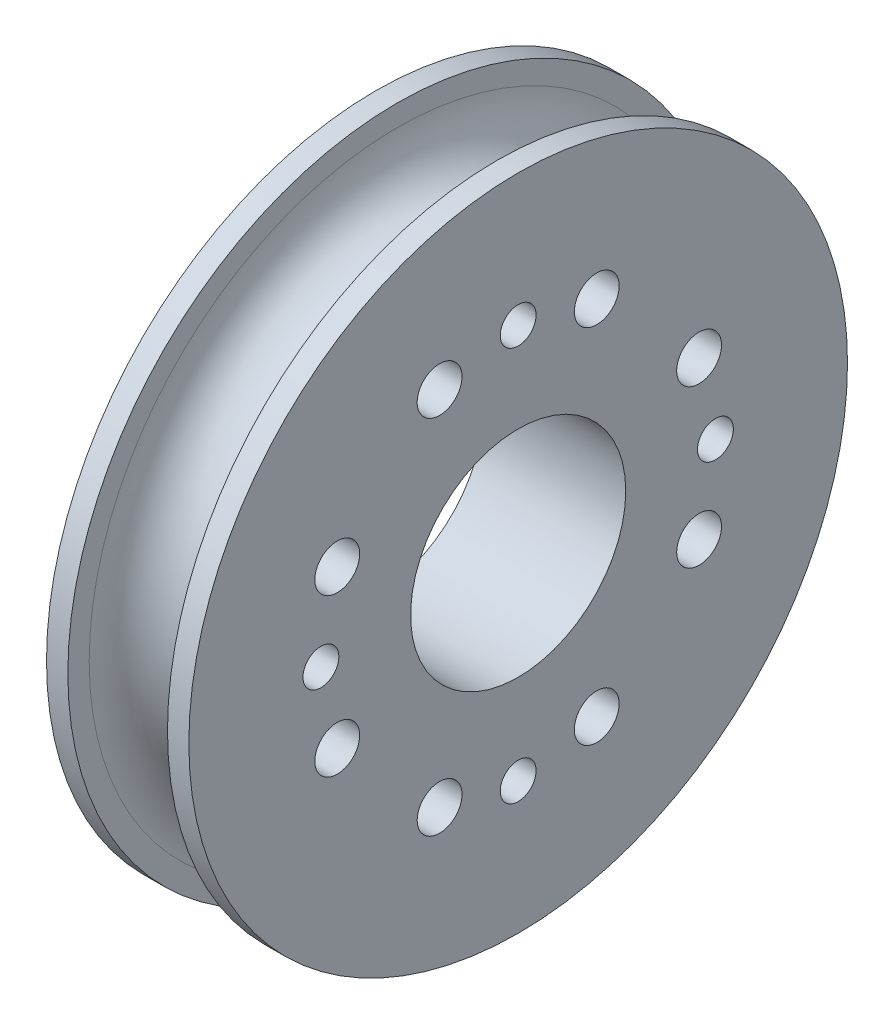
from build123d import *

# Parameters (mm, degrees)
SKETCH3_R      = 6
EXTRUDE1_DEPTH = 8.9375
SKETCH4_R      = 1
SKETCH4_R_2    = 1.25
EXTRUDE2_DEPTH = 8.9375


with BuildPart() as part:
    # Sketch1 → Revolve1 (revolve)
    with BuildSketch(Plane.XY):
        with BuildLine():
            Line((0, 0), (7.9375, 0))
            Line((7.9375, 0), (7.9375, 14))
            Line((7.9375, 14), (7.9375, 17.175))
            Line((7.9375, 17.175), (7.9375, 18.365625))
            Line((7.9375, 18.365625), (6.746875, 18.365625))
            Line((6.746875, 18.365625), (6.746875, 17.175))
            ThreePointArc((6.746875, 17.175), (3.96875, 14.396875), (1.190625, 17.175))
            Line((1.190625, 17.175), (1.190625, 18.365625))
            Line((1.190625, 18.365625), (0, 18.365625))
            Line((0, 18.365625), (0, 17.175))
            Line((0, 17.175), (0, 14))
            Line((0, 14), (0, 0))
        make_face()
    revolve(axis=Axis((0, 0, 0), (1, 0, 0)))

    # Sketch3 → Extrude1 (cut, through all)
    with BuildSketch(Plane(origin=(7.9375, 0, 0), x_dir=(0, 0, -1), z_dir=(1, 0, 0))):
        Circle(SKETCH3_R)
    extrude(amount=-EXTRUDE1_DEPTH, mode=Mode.SUBTRACT)

    # Sketch4 → Extrude2 (cut, through all)
    with BuildSketch(Plane(origin=(7.9375, 0, 0), x_dir=(0, 0, -1), z_dir=(1, 0, 0))):
        with Locations((0, 11)):
            Circle(SKETCH4_R)
        with Locations((-4.381841494, 10.089572098)):
            Circle(SKETCH4_R_2)
        with Locations((4.381841494, 10.089572098)):
            Circle(SKETCH4_R_2)
        with Locations((10.089572098, -4.381841494)):
            Circle(SKETCH4_R_2)
        with Locations((11, 0)):
            Circle(SKETCH4_R)
        with Locations((10.089572098, 4.381841494)):
            Circle(SKETCH4_R_2)
        with Locations((-4.381841494, -10.089572098)):
            Circle(SKETCH4_R_2)
        with Locations((0, -11)):
            Circle(SKETCH4_R)
        with Locations((4.381841494, -10.089572098)):
            Circle(SKETCH4_R_2)
        with Locations((-10.089572098, 4.381841494)):
            Circle(SKETCH4_R_2)
        with Locations((-11, 0)):
            Circle(SKETCH4_R)
        with Locations((-10.089572098, -4.381841494)):
            Circle(SKETCH4_R_2)
    extrude(amount=-EXTRUDE2_DEPTH, mode=Mode.SUBTRACT)


solid = part.part
